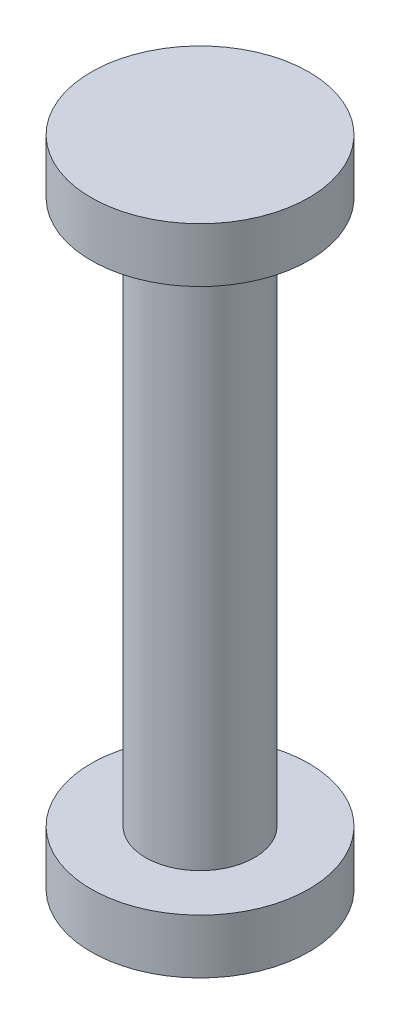
from build123d import *

# Parameters (mm, degrees)
SKETCH1_R           = 5
BOSS_EXTRUDE1_DEPTH = 25
SKETCH2_R           = 10
BOSS_EXTRUDE3_DEPTH = 5


with BuildPart() as part:
    # Sketch1 → Boss-Extrude1 (new body, symmetric)
    with BuildSketch(Plane(origin=(0, 0, 0), x_dir=(1, 0, 0), z_dir=(0, 1, 0))):
        Circle(SKETCH1_R)
    extrude(amount=BOSS_EXTRUDE1_DEPTH, both=True)

    # Sketch2 → Boss-Extrude3 (add)
    with BuildSketch(Plane.XZ.offset(25)):
        Circle(SKETCH2_R)
    boss_extrude3 = extrude(amount=BOSS_EXTRUDE3_DEPTH)

    # Mirror1: Boss-Extrude3 across plane
    add(boss_extrude3.mirror(Plane.ZX))


solid = part.part
